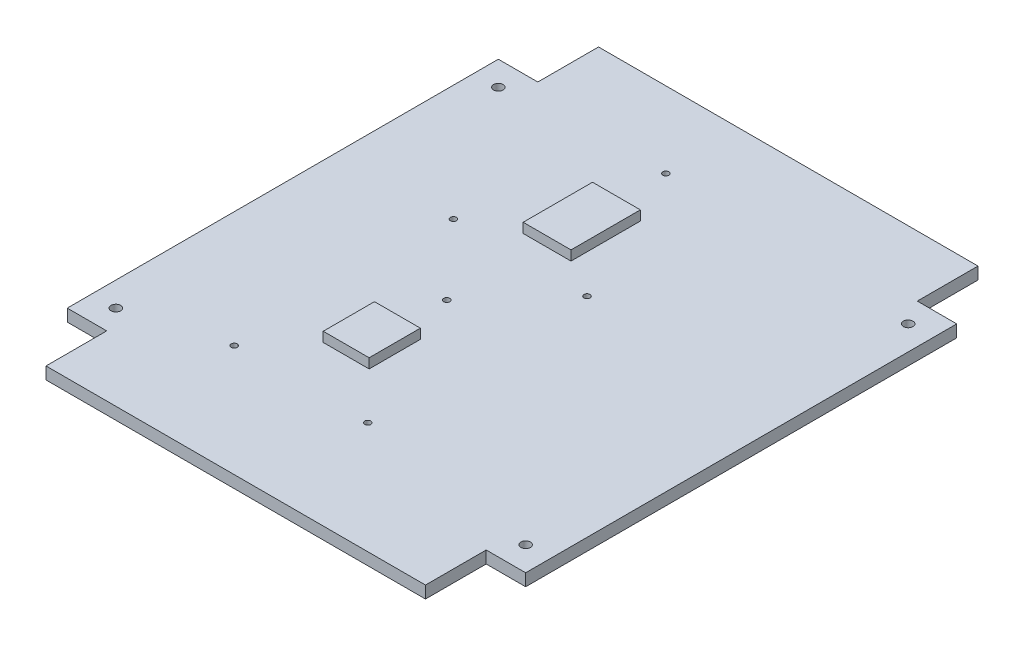
from build123d import *

# Parameters (mm, degrees)
BOSS_EXTRUDE1_DEPTH = 2.54
SKETCH3_W           = 9.6012
SKETCH3_H           = 10.7188
SKETCH3_W_2         = 10.0076
SKETCH3_H_2         = 14.5034
BOSS_EXTRUDE2_DEPTH = 4.572
SKETCH4_R           = 0.635
CUT_EXTRUDE1_DEPTH  = 3.54
SKETCH5_R           = 0.99949
CUT_EXTRUDE2_DEPTH  = 3.54


with BuildPart() as part:
    # Sketch1 → Boss-Extrude1 (new body)
    with BuildSketch(Plane(origin=(0, 0, 0), x_dir=(1, 0, 0), z_dir=(0, 1, 0))):
        Polygon((-47.9425, 45.085), (-39.6875, 45.085), (-39.6875, 57.785), (39.6875, 57.785), (39.6875, 45.085), (47.9425, 45.085), (47.9425, -45.085), (39.6875, -45.085), (39.6875, -57.785), (-39.6875, -57.785), (-39.6875, -45.085), (-47.9425, -45.085), align=None)
    extrude(amount=BOSS_EXTRUDE1_DEPTH)

    # Sketch3 → Boss-Extrude2 (add)
    with BuildSketch(Plane(origin=(0, 0, 0), x_dir=(1, 0, 0), z_dir=(0, 1, 0))):
        with Locations((-10.1473, -19.177)):
            Rectangle(SKETCH3_W, SKETCH3_H)
        with Locations((-8.7757, 23.368)):
            Rectangle(SKETCH3_W_2, SKETCH3_H_2)
    extrude(amount=BOSS_EXTRUDE2_DEPTH)

    # Sketch4 → Cut-Extrude1 (cut, through all)
    with BuildSketch(Plane(origin=(0, 2.54, 0), x_dir=(1, 0, 0), z_dir=(0, 1, 0))):
        with Locations((4.2545, -34.417)):
            Circle(SKETCH4_R)
        with Locations((-23.6855, -34.417)):
            Circle(SKETCH4_R)
        with Locations((-9.7155, -3.937)):
            Circle(SKETCH4_R)
        with Locations((4.2545, 11.43)):
            Circle(SKETCH4_R)
        with Locations((-23.6855, 11.43)):
            Circle(SKETCH4_R)
        with Locations((-9.7155, 41.91)):
            Circle(SKETCH4_R)
    extrude(amount=-CUT_EXTRUDE1_DEPTH, mode=Mode.SUBTRACT)

    # Sketch5 → Cut-Extrude2 (cut, through all)
    with BuildSketch(Plane(origin=(0, 2.54, 0), x_dir=(1, 0, 0), z_dir=(0, 1, 0))):
        with Locations((42.8625, -40.005)):
            Circle(SKETCH5_R)
        with Locations((42.8625, 40.005)):
            Circle(SKETCH5_R)
        with Locations((-42.8625, -40.005)):
            Circle(SKETCH5_R)
        with Locations((-42.8625, 40.005)):
            Circle(SKETCH5_R)
    extrude(amount=-CUT_EXTRUDE2_DEPTH, mode=Mode.SUBTRACT)


solid = part.part
